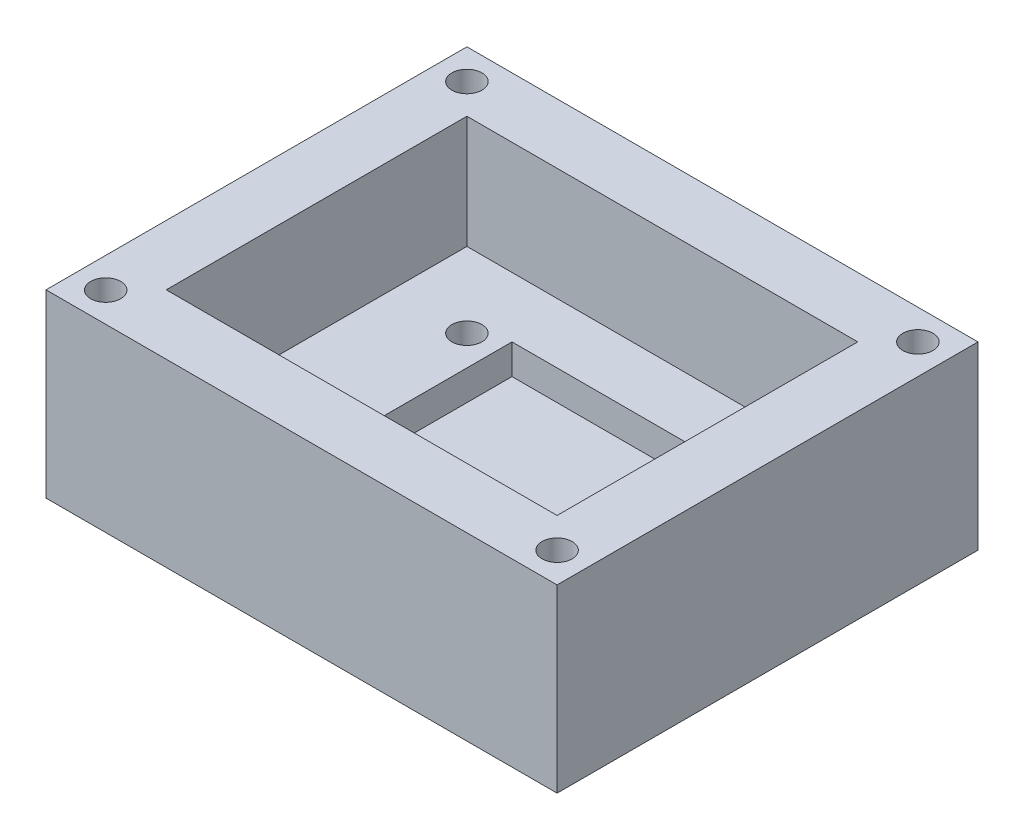
from build123d import *

# Parameters (mm, degrees)
SKETCH1_W           = 43.18
SKETCH1_H           = 35.56
BOSS_EXTRUDE1_DEPTH = 15.24
SKETCH2_W           = 33.02
SKETCH2_H           = 25.4
CUT_EXTRUDE1_DEPTH  = 9.525
SKETCH4_W           = 15.24
SKETCH4_H           = 15.24
CUT_EXTRUDE2_DEPTH  = 2.54
SKETCH7_R           = 1.27
CUT_EXTRUDE3_DEPTH  = 6.715
SKETCH8_R           = 1.27
CUT_EXTRUDE4_DEPTH  = 16.24


with BuildPart() as part:
    # Sketch1 → Boss-Extrude1 (new body)
    with BuildSketch(Plane(origin=(0, 0, 0), x_dir=(1, 0, 0), z_dir=(0, 1, 0))):
        with Locations((4.895164319, -9.074835681)):
            Rectangle(SKETCH1_W, SKETCH1_H)
    extrude(amount=BOSS_EXTRUDE1_DEPTH)

    # Sketch2 → Cut-Extrude1 (cut)
    with BuildSketch(Plane(origin=(0, 15.24, 0), x_dir=(1, 0, 0), z_dir=(0, 1, 0))):
        with Locations((4.895164319, -9.074835681)):
            Rectangle(SKETCH2_W, SKETCH2_H)
    extrude(amount=-CUT_EXTRUDE1_DEPTH, mode=Mode.SUBTRACT)

    # Sketch4 → Cut-Extrude2 (cut)
    with BuildSketch(Plane(origin=(0, 5.715, 0), x_dir=(1, 0, 0), z_dir=(0, 1, 0))):
        with Locations((4.895164319, -9.074835681)):
            Rectangle(SKETCH4_W, SKETCH4_H)
    extrude(amount=-CUT_EXTRUDE2_DEPTH, mode=Mode.SUBTRACT)

    # Sketch7 → Cut-Extrude3 (cut, through all)
    with BuildSketch(Plane(origin=(0, 5.715, 0), x_dir=(1, 0, 0), z_dir=(0, 1, 0))):
        with Locations((-5.264835681, -2.724835681)):
            Circle(SKETCH7_R)
        with Locations((-5.264835681, -15.424835681)):
            Circle(SKETCH7_R)
        with Locations((15.055164319, -2.724835681)):
            Circle(SKETCH7_R)
        with Locations((15.055164319, -15.424835681)):
            Circle(SKETCH7_R)
    extrude(amount=-CUT_EXTRUDE3_DEPTH, mode=Mode.SUBTRACT)

    # Sketch8 → Cut-Extrude4 (cut, through all)
    with BuildSketch(Plane(origin=(0, 15.24, 0), x_dir=(1, 0, 0), z_dir=(0, 1, 0))):
        with Locations((-14.154835681, 6.165164319)):
            Circle(SKETCH8_R)
        with Locations((-14.154835681, -24.353191234)):
            Circle(SKETCH8_R)
        with Locations((23.945164319, 6.165164319)):
            Circle(SKETCH8_R)
        with Locations((23.945164319, -24.314835681)):
            Circle(SKETCH8_R)
    extrude(amount=-CUT_EXTRUDE4_DEPTH, mode=Mode.SUBTRACT)


solid = part.part
